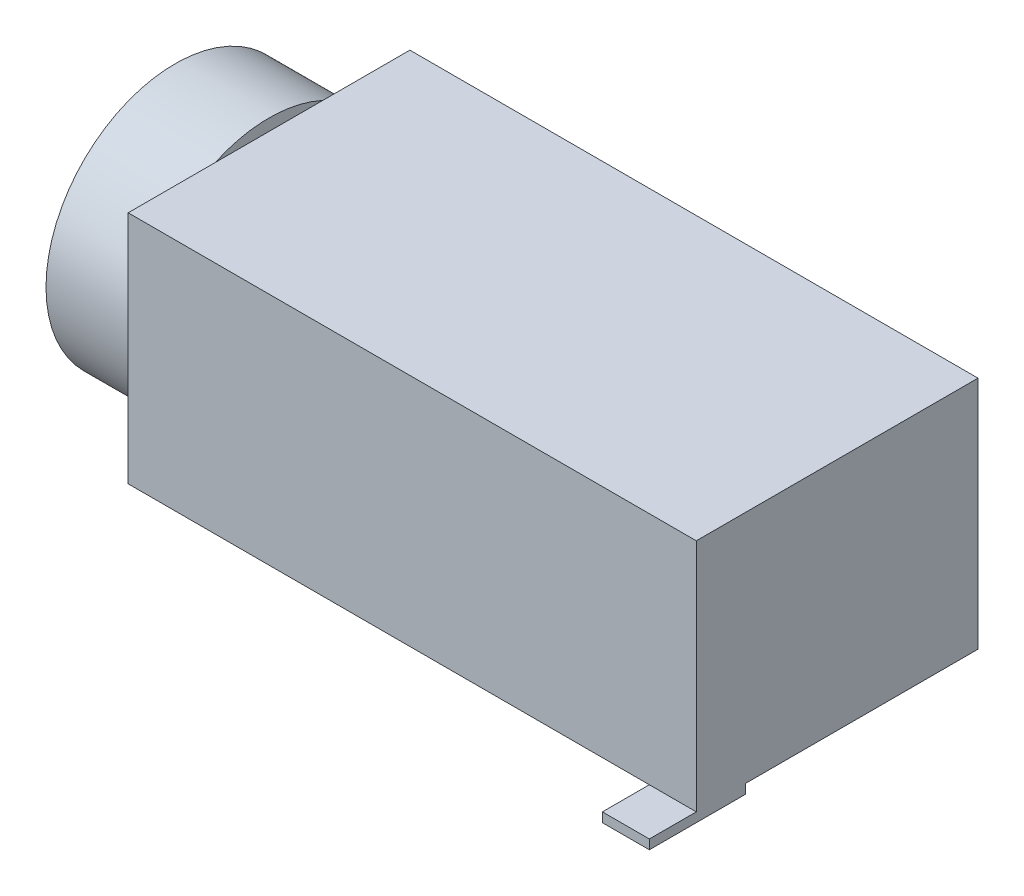
from build123d import *

# Parameters (mm, degrees)
SKETCH1_W           = 12.1
SKETCH1_H           = 6
BOSS_EXTRUDE1_DEPTH = 2.5
SKETCH2_R           = 2.75
SKETCH2_R_2         = 1.8
BOSS_EXTRUDE2_DEPTH = 2
SKETCH3_R           = 0.6
BOSS_EXTRUDE3_DEPTH = 0.8
FILLET1_R           = 0.2
SKETCH4_W           = 1
SKETCH4_H           = 2.460309858
SKETCH4_H_2         = 2.047502849
BOSS_EXTRUDE4_DEPTH = 0.2


with BuildPart() as part:
    # Sketch1 → Boss-Extrude1 (new body, symmetric)
    with BuildSketch(Plane(origin=(0, 0, 0), x_dir=(1, 0, 0), z_dir=(0, 1, 0))):
        Rectangle(SKETCH1_W, SKETCH1_H)
    extrude(amount=BOSS_EXTRUDE1_DEPTH, both=True)

    # Sketch2 → Boss-Extrude2 (add)
    with BuildSketch(Plane.ZY.offset(6.05)):
        Circle(SKETCH2_R)
        Circle(SKETCH2_R_2, mode=Mode.SUBTRACT)
    extrude(amount=BOSS_EXTRUDE2_DEPTH)

    # Sketch3 → Boss-Extrude3 (add)
    with BuildSketch(Plane.XZ.offset(2.5)):
        with Locations((-4.25, 0)):
            Circle(SKETCH3_R)
        with Locations((2.75, 0)):
            Circle(SKETCH3_R)
    extrude(amount=BOSS_EXTRUDE3_DEPTH)

    # Fillet1
    fillet1_edges = [part.edges().sort_by_distance(p)[0] for p in [
        (-4.85, -3.3, 0),
        (2.15, -3.3, 0),
    ]]
    fillet(fillet1_edges, radius=FILLET1_R)

    # Sketch4 → Boss-Extrude4 (add)
    with BuildSketch(Plane.XZ.offset(2.5)):
        with Locations((-2.95, -2.769845071)):
            Rectangle(SKETCH4_W, SKETCH4_H)
        with Locations((0.05, -2.769845071)):
            Rectangle(SKETCH4_W, SKETCH4_H)
        with Locations((4.05, -2.769845071)):
            Rectangle(SKETCH4_W, SKETCH4_H)
        with Locations((5.55, 2.976248576)):
            Rectangle(SKETCH4_W, SKETCH4_H_2)
    extrude(amount=BOSS_EXTRUDE4_DEPTH)


solid = part.part
